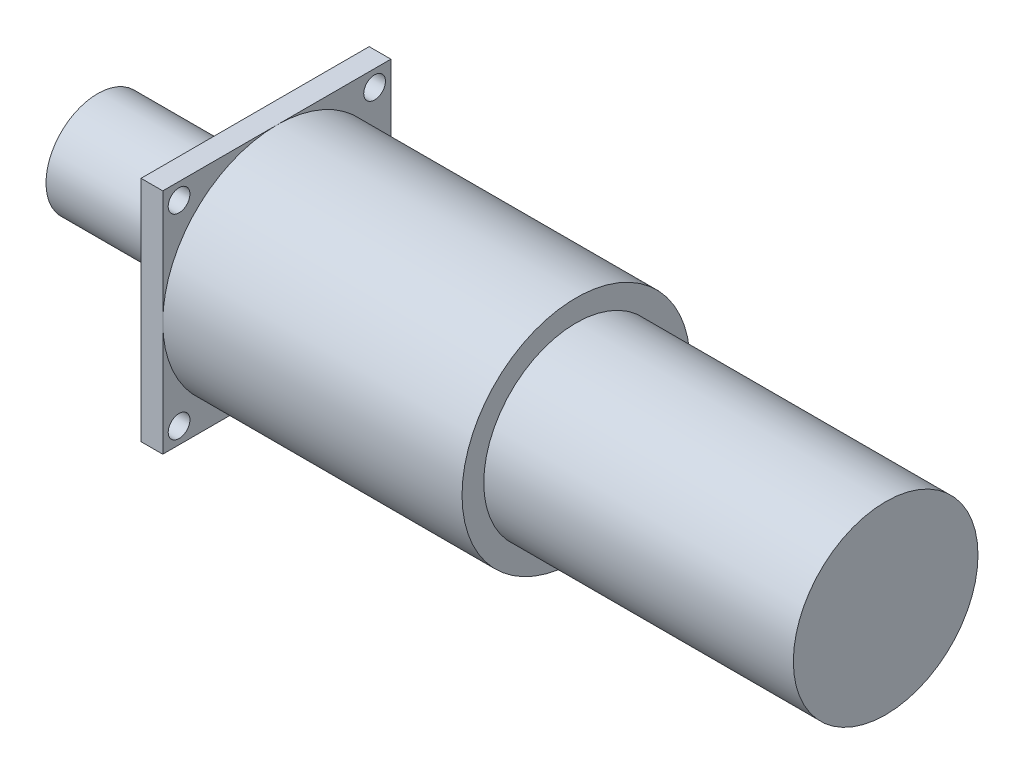
from build123d import *

# Parameters (mm, degrees)
ESBO_O2_W                = 42
ESBO_O2_H                = 42
RESSALTO_EXTRUS_O1_DEPTH = 4
ESBO_O3_R                = 2
CORTE_EXTRUS_O1_DEPTH    = 4


with BuildPart() as part:
    # Esboço1 → Revolução1 (revolve)
    with BuildSketch(Plane.XY):
        Polygon((-29, 0), (-29, 9.5), (-11.2, 9.5), (-11.2, 4), (-3.7, 4), (-3.7, 15), (0, 15), (0, 21), (59.1, 21), (59.1, 17), (116.1, 17), (116.1, 0), align=None)
    revolve(axis=Axis((0, 0, 0), (1, 0, 0)))

    # Esboço2 → Ressalto-extrusão1 (add)
    with BuildSketch(Plane.ZY):
        Rectangle(ESBO_O2_W, ESBO_O2_H)
    extrude(amount=-RESSALTO_EXTRUS_O1_DEPTH)

    # Esboço3 → Corte-extrusão1 (cut)
    with BuildSketch(Plane(origin=(4, 0, 0), x_dir=(0, 0, -1), z_dir=(1, 0, 0))):
        with Locations((-18, 18)):
            Circle(ESBO_O3_R)
        with Locations((-18, -18)):
            Circle(ESBO_O3_R)
        with Locations((18, -18)):
            Circle(ESBO_O3_R)
        with Locations((18, 18)):
            Circle(ESBO_O3_R)
    extrude(amount=-CORTE_EXTRUS_O1_DEPTH, mode=Mode.SUBTRACT)


solid = part.part
